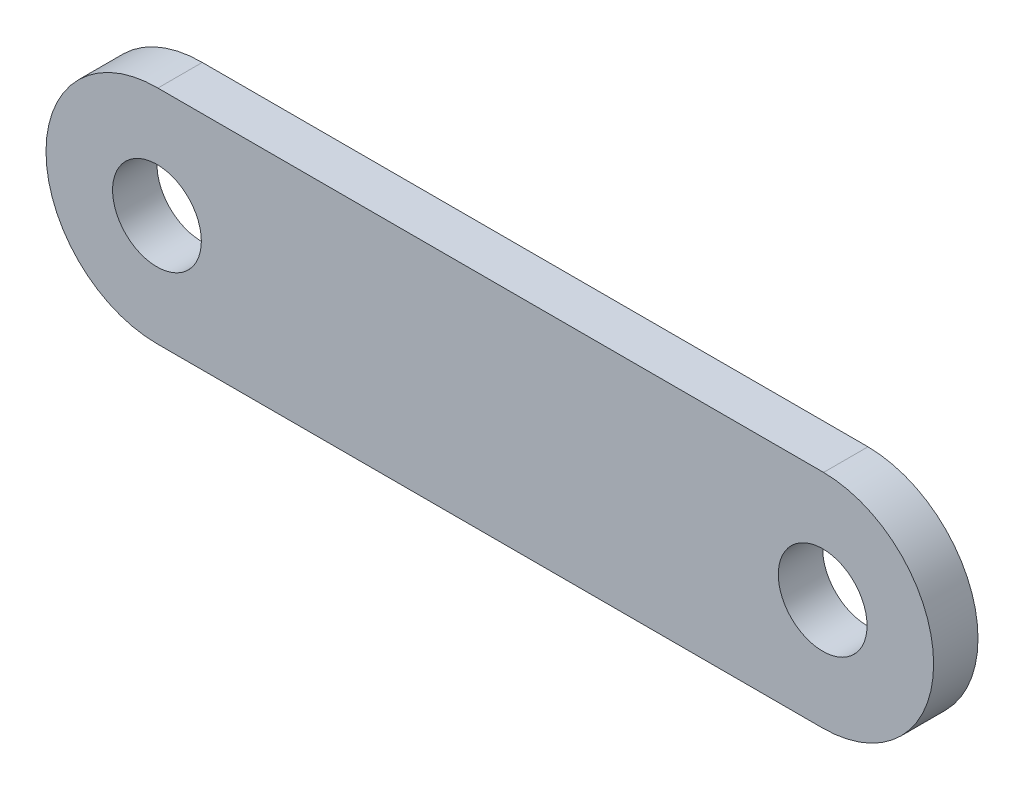
from build123d import *

# Parameters (mm, degrees)
SKETCH1_R           = 1
BOSS_EXTRUDE1_DEPTH = 1


with BuildPart() as part:
    # Sketch1 → Boss-Extrude1 (new body)
    with BuildSketch(Plane.XY):
        with BuildLine():
            Line((-0.021163243, 2.499910422), (-14.978836757, 2.499910422))
            ThreePointArc((-14.978836757, 2.499910422), (-17.499977605, 0.010581716), (-15, -2.5))
            Line((-15, -2.5), (0, -2.5))
            ThreePointArc((0, -2.5), (2.499977605, -0.010581716), (0.021163243, 2.499910422))
            Line((0.021163243, 2.499910422), (-0.021163243, 2.499910422))
        make_face()
        with Locations((-15, 0)):
            Circle(SKETCH1_R, mode=Mode.SUBTRACT)
        Circle(SKETCH1_R, mode=Mode.SUBTRACT)
    extrude(amount=BOSS_EXTRUDE1_DEPTH)


solid = part.part
